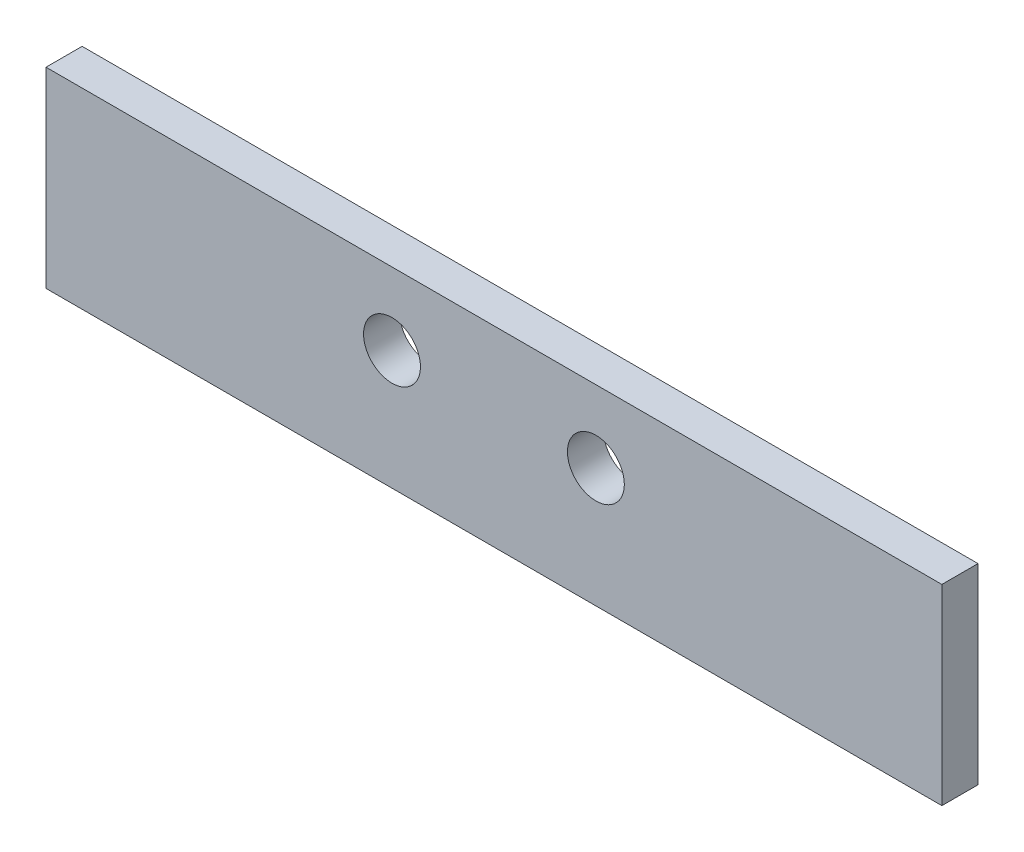
from build123d import *

# Parameters (mm, degrees)
SKETCH1_W           = 78.74
SKETCH1_H           = 16.8402
BOSS_EXTRUDE1_DEPTH = 3.175
SKETCH2_R           = 2.5
CUT_EXTRUDE1_DEPTH  = 4.175


with BuildPart() as part:
    # Sketch1 → Boss-Extrude1 (new body)
    with BuildSketch(Plane.XY):
        Rectangle(SKETCH1_W, SKETCH1_H)
    extrude(amount=BOSS_EXTRUDE1_DEPTH)

    # Sketch2 → Cut-Extrude1 (cut, through all)
    with BuildSketch(Plane.XY.offset(3.175)):
        with Locations((-8.95985, 2.0701)):
            Circle(SKETCH2_R)
        with Locations((8.95985, 2.0701)):
            Circle(SKETCH2_R)
    extrude(amount=-CUT_EXTRUDE1_DEPTH, mode=Mode.SUBTRACT)


solid = part.part
